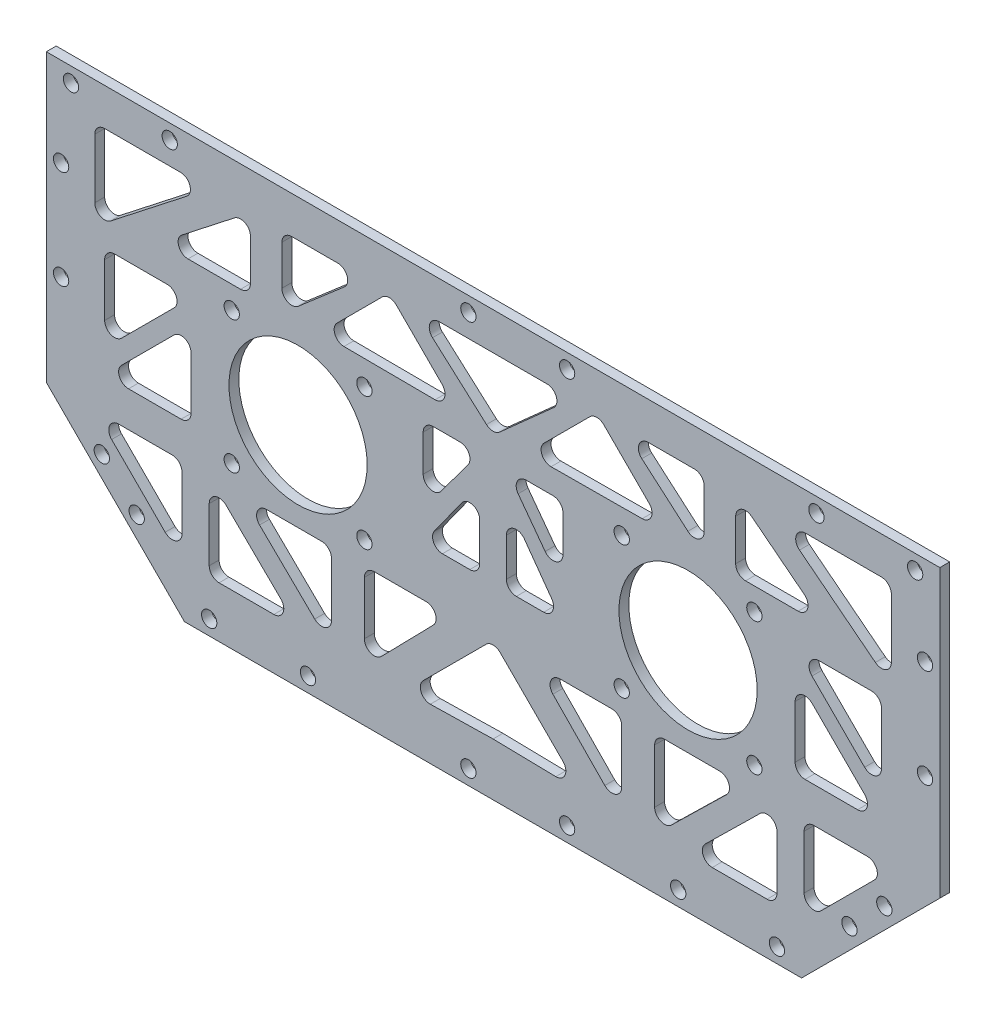
from build123d import *

# Parameters (mm, degrees)
SKETCH_1_R      = 1.55
SKETCH_1_R_2    = 14
EXTRUDE_1_DEPTH = 2


with BuildPart() as part:
    # 草图1 → 凸台-拉伸1 (new body)
    with BuildSketch(Plane.XY):
        Polygon((-90.5, 18), (-90.5, -18), (-62.5, -46), (62.5, -46), (90.5, -18), (90.5, 18), (90.5, 39.999559912), (-90.5, 39.999559912), align=None)
        with Locations((-52.935028843, -13.435028843)):
            Circle(SKETCH_1_R, mode=Mode.SUBTRACT)
        with Locations((-52.935028843, 13.435028843)):
            Circle(SKETCH_1_R, mode=Mode.SUBTRACT)
        with Locations((-26.064971157, -13.435028843)):
            Circle(SKETCH_1_R, mode=Mode.SUBTRACT)
        with Locations((-26.064971157, 13.435028843)):
            Circle(SKETCH_1_R, mode=Mode.SUBTRACT)
        with Locations((-39.5, 0)):
            Circle(SKETCH_1_R_2, mode=Mode.SUBTRACT)
        with Locations((39.5, 0)):
            Circle(SKETCH_1_R_2, mode=Mode.SUBTRACT)
        with Locations((57.5, -43)):
            Circle(SKETCH_1_R, mode=Mode.SUBTRACT)
        with Locations((37.5, -43)):
            Circle(SKETCH_1_R, mode=Mode.SUBTRACT)
        with Locations((-57.5, -43)):
            Circle(SKETCH_1_R, mode=Mode.SUBTRACT)
        with Locations((-37.5, -43)):
            Circle(SKETCH_1_R, mode=Mode.SUBTRACT)
        with Locations((-85.5, 37)):
            Circle(SKETCH_1_R, mode=Mode.SUBTRACT)
        with Locations((-65.5, 37)):
            Circle(SKETCH_1_R, mode=Mode.SUBTRACT)
        with Locations((65.5, 37)):
            Circle(SKETCH_1_R, mode=Mode.SUBTRACT)
        with Locations((85.5, 37)):
            Circle(SKETCH_1_R, mode=Mode.SUBTRACT)
        with Locations((15, -43)):
            Circle(SKETCH_1_R, mode=Mode.SUBTRACT)
        with Locations((-5, -43)):
            Circle(SKETCH_1_R, mode=Mode.SUBTRACT)
        with Locations((-5, 37)):
            Circle(SKETCH_1_R, mode=Mode.SUBTRACT)
        with Locations((15, 37)):
            Circle(SKETCH_1_R, mode=Mode.SUBTRACT)
        with Locations((-87.5, 21.999559912)):
            Circle(SKETCH_1_R, mode=Mode.SUBTRACT)
        with Locations((-87.5, 1.999559912)):
            Circle(SKETCH_1_R, mode=Mode.SUBTRACT)
        with Locations((87.5, 21.999559912)):
            Circle(SKETCH_1_R, mode=Mode.SUBTRACT)
        with Locations((87.5, 1.999559912)):
            Circle(SKETCH_1_R, mode=Mode.SUBTRACT)
        with Locations((26.064971157, 13.435028843)):
            Circle(SKETCH_1_R, mode=Mode.SUBTRACT)
        with Locations((52.935028843, 13.435028843)):
            Circle(SKETCH_1_R, mode=Mode.SUBTRACT)
        with Locations((52.935028843, -13.435028843)):
            Circle(SKETCH_1_R, mode=Mode.SUBTRACT)
        with Locations((26.064971157, -13.435028843)):
            Circle(SKETCH_1_R, mode=Mode.SUBTRACT)
        with Locations((79.257359313, -25)):
            Circle(SKETCH_1_R, mode=Mode.SUBTRACT)
        with Locations((72.186291501, -32.071067812)):
            Circle(SKETCH_1_R, mode=Mode.SUBTRACT)
        with Locations((-79.257359313, -25)):
            Circle(SKETCH_1_R, mode=Mode.SUBTRACT)
        with Locations((-72.186291501, -32.071067812)):
            Circle(SKETCH_1_R, mode=Mode.SUBTRACT)
        with BuildLine():
            Line((-77.263881929, -21.414213562), (-66.42156419, -32.256531302))
            ThreePointArc((-66.42156419, -32.256531302), (-64.241983763, -32.690076804), (-63.007350628, -30.842317739))
            Line((-63.007350628, -30.842317739), (-63.007350628, -20))
            ThreePointArc((-63.007350628, -20), (-63.593137065, -18.585786438), (-65.007350628, -18))
            Line((-65.007350628, -18), (-75.849668367, -18))
            ThreePointArc((-75.849668367, -18), (-77.697427432, -19.234633135), (-77.263881929, -21.414213562))
        make_face(mode=Mode.SUBTRACT)
        with BuildLine():
            Line((-57.5, -22.766093881), (-57.5, -33.670744864))
            ThreePointArc((-57.5, -33.670744864), (-56.914213562, -35.084958427), (-55.5, -35.670744864))
            Line((-55.5, -35.670744864), (-44.392165033, -35.670744864))
            ThreePointArc((-44.392165033, -35.670744864), (-42.540893438, -34.427576076), (-42.991064909, -32.243538347))
            Line((-42.991064909, -32.243538347), (-54.098899876, -21.338887364))
            ThreePointArc((-54.098899876, -21.338887364), (-56.273886216, -20.921886701), (-57.5, -22.766093881))
        make_face(mode=Mode.SUBTRACT)
        with BuildLine():
            Line((-45.902098374, -18), (-34.733622377, -18))
            ThreePointArc((-34.733622377, -18), (-33.319408815, -18.585786438), (-32.733622377, -20))
            Line((-32.733622377, -20), (-32.733622377, -30.918543334))
            ThreePointArc((-32.733622377, -30.918543334), (-33.957813813, -32.761942658), (-36.131743448, -32.348668318))
            Line((-36.131743448, -32.348668318), (-47.300219444, -21.430124985))
            ThreePointArc((-47.300219444, -21.430124985), (-47.754158034, -19.245099334), (-45.902098374, -18))
        make_face(mode=Mode.SUBTRACT)
        with BuildLine():
            Line((-26.064971157, -20), (-26.064971157, -30.763980984))
            ThreePointArc((-26.064971157, -30.763980984), (-24.819871823, -32.616040644), (-22.634846173, -32.162102055))
            Line((-22.634846173, -32.162102055), (-12.111745899, -21.398121071))
            ThreePointArc((-12.111745899, -21.398121071), (-11.698471559, -19.224191435), (-13.541870884, -18))
            Line((-13.541870884, -18), (-24.064971157, -18))
            ThreePointArc((-24.064971157, -18), (-25.47918472, -18.585786438), (-26.064971157, -20))
        make_face(mode=Mode.SUBTRACT)
        with BuildLine():
            Line((-1.414213562, -19.414213562), (-14.157611456, -32.157611456))
            ThreePointArc((-14.157611456, -32.157611456), (-14.583414209, -34.355623436), (-12.703416777, -35.571425356))
            Line((-12.703416777, -35.571425356), (0, -35.317426206))
            Line((0, -35.317426206), (12.703416777, -35.571425356))
            ThreePointArc((12.703416777, -35.571425356), (14.583414209, -34.355623436), (14.157611456, -32.157611456))
            Line((14.157611456, -32.157611456), (1.414213562, -19.414213562))
            ThreePointArc((1.414213562, -19.414213562), (0, -18.828427125), (-1.414213562, -19.414213562))
        make_face(mode=Mode.SUBTRACT)
        with BuildLine():
            Line((-80.678095492, 30.432432432), (-80.678095492, 18.411131003))
            ThreePointArc((-80.678095492, 18.411131003), (-79.554468645, 16.613362915), (-77.446125395, 16.835615316))
            Line((-77.446125395, 16.835615316), (-62.072579374, 28.856916745))
            ThreePointArc((-62.072579374, 28.856916745), (-61.413646066, 31.083957039), (-63.304549471, 32.432432432))
            Line((-63.304549471, 32.432432432), (-78.678095492, 32.432432432))
            ThreePointArc((-78.678095492, 32.432432432), (-80.092309054, 31.846645995), (-80.678095492, 30.432432432))
        make_face(mode=Mode.SUBTRACT)
        with BuildLine():
            Line((-52.377008029, 29.90520243), (-63.02950046, 21.575515687))
            ThreePointArc((-63.02950046, 21.575515687), (-63.688433768, 19.348475393), (-61.797530363, 18))
            Line((-61.797530363, 18), (-51.145037932, 18))
            ThreePointArc((-51.145037932, 18), (-49.73082437, 18.585786438), (-49.145037932, 20))
            Line((-49.145037932, 20), (-49.145037932, 28.329686743))
            ThreePointArc((-49.145037932, 28.329686743), (-50.26866478, 30.127454831), (-52.377008029, 29.90520243))
        make_face(mode=Mode.SUBTRACT)
        with BuildLine():
            Line((-1.331450567, 19.187863793), (-12.262450182, 28.940038588))
            ThreePointArc((-12.262450182, 28.940038588), (-12.799794372, 31.144897277), (-10.930999615, 32.432432432))
            Line((-10.930999615, 32.432432432), (10.930999615, 32.432432432))
            ThreePointArc((10.930999615, 32.432432432), (12.799794372, 31.144897277), (12.262450182, 28.940038588))
            Line((12.262450182, 28.940038588), (1.331450567, 19.187863793))
            ThreePointArc((1.331450567, 19.187863793), (0, 18.680257637), (-1.331450567, 19.187863793))
        make_face(mode=Mode.SUBTRACT)
        with BuildLine():
            Line((-42.775449992, 30.432432432), (-42.775449992, 22.370028204))
            ThreePointArc((-42.775449992, 22.370028204), (-41.607751779, 20.551437064), (-39.468176256, 20.856411549))
            Line((-39.468176256, 20.856411549), (-30.133184677, 28.918815777))
            ThreePointArc((-30.133184677, 28.918815777), (-29.565994049, 31.129844323), (-31.440458414, 32.432432432))
            Line((-31.440458414, 32.432432432), (-40.775449992, 32.432432432))
            ThreePointArc((-40.775449992, 32.432432432), (-42.189663555, 31.846645995), (-42.775449992, 30.432432432))
        make_face(mode=Mode.SUBTRACT)
        with BuildLine():
            Line((-19.604584432, 31.01821887), (-10.31794403, 21.731578468))
            ThreePointArc((-10.31794403, 21.731578468), (-9.886718054, 19.546422036), (-11.744235939, 18.317401378))
            Line((-11.744235939, 18.317401378), (-30.206020791, 18.42889733))
            ThreePointArc((-30.206020791, 18.42889733), (-32.044004188, 19.669076976), (-31.608156007, 21.84307442))
            Line((-31.608156007, 21.84307442), (-22.433011557, 31.01821887))
            ThreePointArc((-22.433011557, 31.01821887), (-21.018797995, 31.604005308), (-19.604584432, 31.01821887))
        make_face(mode=Mode.SUBTRACT)
        with BuildLine():
            Line((63.007350628, -30.842317739), (63.007350628, -20))
            ThreePointArc((63.007350628, -20), (63.593137065, -18.585786438), (65.007350628, -18))
            Line((65.007350628, -18), (75.849668367, -18))
            ThreePointArc((75.849668367, -18), (77.697427432, -19.234633135), (77.263881929, -21.414213562))
            Line((77.263881929, -21.414213562), (66.42156419, -32.256531302))
            ThreePointArc((66.42156419, -32.256531302), (64.241983763, -32.690076804), (63.007350628, -30.842317739))
        make_face(mode=Mode.SUBTRACT)
        with BuildLine():
            Line((55.5, -35.670744864), (44.392165033, -35.670744864))
            ThreePointArc((44.392165033, -35.670744864), (42.540893438, -34.427576076), (42.991064909, -32.243538347))
            Line((42.991064909, -32.243538347), (54.098899876, -21.338887364))
            ThreePointArc((54.098899876, -21.338887364), (56.273886216, -20.921886701), (57.5, -22.766093881))
            Line((57.5, -22.766093881), (57.5, -33.670744864))
            ThreePointArc((57.5, -33.670744864), (56.914213562, -35.084958427), (55.5, -35.670744864))
        make_face(mode=Mode.SUBTRACT)
        with BuildLine():
            Line((32.733622377, -20), (32.733622377, -30.918543334))
            ThreePointArc((32.733622377, -30.918543334), (33.957813813, -32.761942658), (36.131743448, -32.348668318))
            Line((36.131743448, -32.348668318), (47.300219444, -21.430124985))
            ThreePointArc((47.300219444, -21.430124985), (47.754158034, -19.245099334), (45.902098374, -18))
            Line((45.902098374, -18), (34.733622377, -18))
            ThreePointArc((34.733622377, -18), (33.319408815, -18.585786438), (32.733622377, -20))
        make_face(mode=Mode.SUBTRACT)
        with BuildLine():
            Line((22.634846173, -32.162102055), (12.111745899, -21.398121071))
            ThreePointArc((12.111745899, -21.398121071), (11.698471559, -19.224191435), (13.541870884, -18))
            Line((13.541870884, -18), (24.064971157, -18))
            ThreePointArc((24.064971157, -18), (25.47918472, -18.585786438), (26.064971157, -20))
            Line((26.064971157, -20), (26.064971157, -30.763980984))
            ThreePointArc((26.064971157, -30.763980984), (24.819871823, -32.616040644), (22.634846173, -32.162102055))
        make_face(mode=Mode.SUBTRACT)
        with BuildLine():
            Line((77.446125395, 16.835615316), (62.072579374, 28.856916745))
            ThreePointArc((62.072579374, 28.856916745), (61.413646066, 31.083957039), (63.304549471, 32.432432432))
            Line((63.304549471, 32.432432432), (78.678095492, 32.432432432))
            ThreePointArc((78.678095492, 32.432432432), (80.092309054, 31.846645995), (80.678095492, 30.432432432))
            Line((80.678095492, 30.432432432), (80.678095492, 18.411131003))
            ThreePointArc((80.678095492, 18.411131003), (79.554468645, 16.613362915), (77.446125395, 16.835615316))
        make_face(mode=Mode.SUBTRACT)
        with BuildLine():
            Line((61.797530363, 18), (51.145037932, 18))
            ThreePointArc((51.145037932, 18), (49.73082437, 18.585786438), (49.145037932, 20))
            Line((49.145037932, 20), (49.145037932, 28.329686743))
            ThreePointArc((49.145037932, 28.329686743), (50.26866478, 30.127454831), (52.377008029, 29.90520243))
            Line((52.377008029, 29.90520243), (63.02950046, 21.575515687))
            ThreePointArc((63.02950046, 21.575515687), (63.688433768, 19.348475393), (61.797530363, 18))
        make_face(mode=Mode.SUBTRACT)
        with BuildLine():
            Line((39.468176256, 20.856411549), (30.133184677, 28.918815777))
            ThreePointArc((30.133184677, 28.918815777), (29.565994049, 31.129844323), (31.440458414, 32.432432432))
            Line((31.440458414, 32.432432432), (40.775449992, 32.432432432))
            ThreePointArc((40.775449992, 32.432432432), (42.189663555, 31.846645995), (42.775449992, 30.432432432))
            Line((42.775449992, 30.432432432), (42.775449992, 22.370028204))
            ThreePointArc((42.775449992, 22.370028204), (41.607751779, 20.551437064), (39.468176256, 20.856411549))
        make_face(mode=Mode.SUBTRACT)
        with BuildLine():
            Line((11.744235939, 18.317401378), (30.206020791, 18.42889733))
            ThreePointArc((30.206020791, 18.42889733), (32.044004188, 19.669076976), (31.608156007, 21.84307442))
            Line((31.608156007, 21.84307442), (22.433011557, 31.01821887))
            ThreePointArc((22.433011557, 31.01821887), (21.018797995, 31.604005308), (19.604584432, 31.01821887))
            Line((19.604584432, 31.01821887), (10.31794403, 21.731578468))
            ThreePointArc((10.31794403, 21.731578468), (9.886718054, 19.546422036), (11.744235939, 18.317401378))
        make_face(mode=Mode.SUBTRACT)
        with BuildLine():
            Line((-12.157611456, 13.435028843), (-6.680247296, 13.435028843))
            ThreePointArc((-6.680247296, 13.435028843), (-4.893720904, 12.334096944), (-5.074038404, 10.243352294))
            Line((-5.074038404, 10.243352294), (-10.551402564, 2.860651822))
            ThreePointArc((-10.551402564, 2.860651822), (-12.785139231, 2.153326293), (-14.157611456, 4.052328371))
            Line((-14.157611456, 4.052328371), (-14.157611456, 11.435028843))
            ThreePointArc((-14.157611456, 11.435028843), (-13.571825018, 12.849242405), (-12.157611456, 13.435028843))
        make_face(mode=Mode.SUBTRACT)
        with BuildLine():
            Line((-6.330758779, 2.950986991), (-11.88448165, -4.785083259))
            ThreePointArc((-11.88448165, -4.785083259), (-12.039223664, -6.864482622), (-10.259796491, -7.951444323))
            Line((-10.259796491, -7.951444323), (-4.706073619, -7.951444323))
            ThreePointArc((-4.706073619, -7.951444323), (-3.291860057, -7.365657886), (-2.706073619, -5.951444323))
            Line((-2.706073619, -5.951444323), (-2.706073619, 1.784625927))
            ThreePointArc((-2.706073619, 1.784625927), (-4.093444171, 3.68848652), (-6.330758779, 2.950986991))
        make_face(mode=Mode.SUBTRACT)
        with BuildLine():
            Line((10.259796491, -7.951444323), (4.706073619, -7.951444323))
            ThreePointArc((4.706073619, -7.951444323), (3.291860057, -7.365657886), (2.706073619, -5.951444323))
            Line((2.706073619, -5.951444323), (2.706073619, 1.784625927))
            ThreePointArc((2.706073619, 1.784625927), (4.093444171, 3.68848652), (6.330758779, 2.950986991))
            Line((6.330758779, 2.950986991), (11.88448165, -4.785083259))
            ThreePointArc((11.88448165, -4.785083259), (12.039223664, -6.864482622), (10.259796491, -7.951444323))
        make_face(mode=Mode.SUBTRACT)
        with BuildLine():
            Line((14.157611456, 11.435028843), (14.157611456, 4.052328371))
            ThreePointArc((14.157611456, 4.052328371), (12.785139231, 2.153326293), (10.551402564, 2.860651822))
            Line((10.551402564, 2.860651822), (5.074038404, 10.243352294))
            ThreePointArc((5.074038404, 10.243352294), (4.893720904, 12.334096944), (6.680247296, 13.435028843))
            Line((6.680247296, 13.435028843), (12.157611456, 13.435028843))
            ThreePointArc((12.157611456, 13.435028843), (13.571825018, 12.849242405), (14.157611456, 11.435028843))
        make_face(mode=Mode.SUBTRACT)
        with BuildLine():
            Line((-76.678095492, 11.435028843), (-66.015130201, 11.435028843))
            ThreePointArc((-66.015130201, 11.435028843), (-64.167371136, 10.200395707), (-64.600916638, 8.02081528))
            Line((-64.600916638, 8.02081528), (-75.263881929, -2.642150011))
            ThreePointArc((-75.263881929, -2.642150011), (-77.443462356, -3.075695514), (-78.678095492, -1.227936449))
            Line((-78.678095492, -1.227936449), (-78.678095492, 9.435028843))
            ThreePointArc((-78.678095492, 9.435028843), (-78.092309054, 10.849242405), (-76.678095492, 11.435028843))
        make_face(mode=Mode.SUBTRACT)
        with BuildLine():
            Line((-64.600916638, 3.267791168), (-75.263881929, -7.395174123))
            ThreePointArc((-75.263881929, -7.395174123), (-75.697427432, -9.57475455), (-73.849668367, -10.809387685))
            Line((-73.849668367, -10.809387685), (-63.186703076, -10.809387685))
            ThreePointArc((-63.186703076, -10.809387685), (-61.772489514, -10.223601248), (-61.186703076, -8.809387685))
            Line((-61.186703076, -8.809387685), (-61.186703076, 1.853577606))
            ThreePointArc((-61.186703076, 1.853577606), (-62.421336211, 3.701336671), (-64.600916638, 3.267791168))
        make_face(mode=Mode.SUBTRACT)
        with BuildLine():
            Line((73.849668367, -10.809387685), (63.186703076, -10.809387685))
            ThreePointArc((63.186703076, -10.809387685), (61.772489514, -10.223601248), (61.186703076, -8.809387685))
            Line((61.186703076, -8.809387685), (61.186703076, 1.853577606))
            ThreePointArc((61.186703076, 1.853577606), (62.421336211, 3.701336671), (64.600916638, 3.267791168))
            Line((64.600916638, 3.267791168), (75.263881929, -7.395174123))
            ThreePointArc((75.263881929, -7.395174123), (75.697427432, -9.57475455), (73.849668367, -10.809387685))
        make_face(mode=Mode.SUBTRACT)
        with BuildLine():
            Line((64.600916638, 8.02081528), (75.263881929, -2.642150011))
            ThreePointArc((75.263881929, -2.642150011), (77.443462356, -3.075695514), (78.678095492, -1.227936449))
            Line((78.678095492, -1.227936449), (78.678095492, 9.435028843))
            ThreePointArc((78.678095492, 9.435028843), (78.092309054, 10.849242405), (76.678095492, 11.435028843))
            Line((76.678095492, 11.435028843), (66.015130201, 11.435028843))
            ThreePointArc((66.015130201, 11.435028843), (64.167371136, 10.200395707), (64.600916638, 8.02081528))
        make_face(mode=Mode.SUBTRACT)
    extrude(amount=EXTRUDE_1_DEPTH)


solid = part.part
